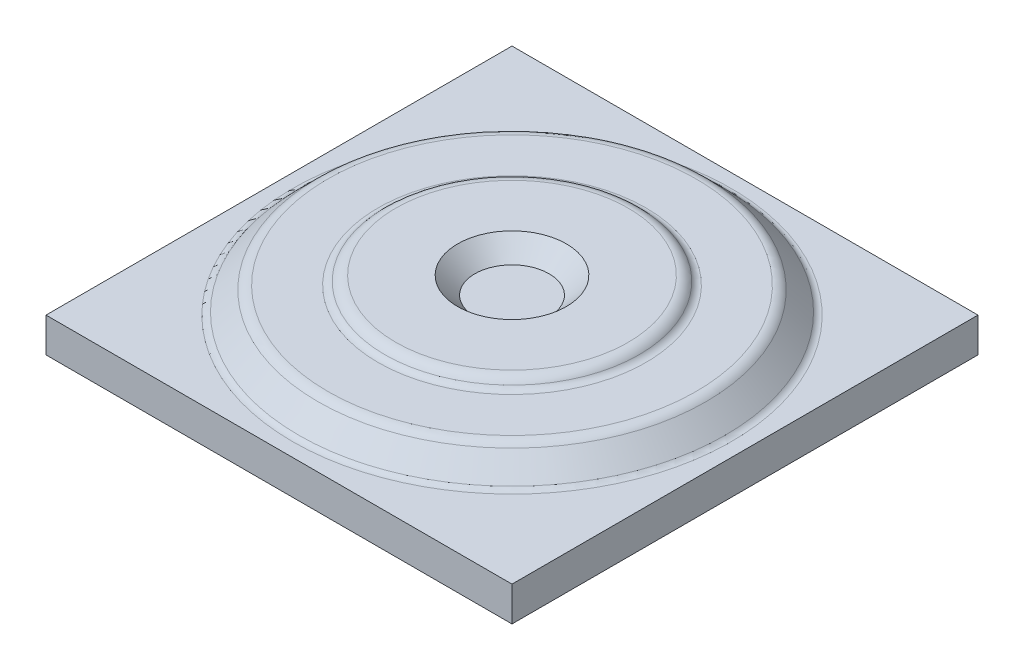
from build123d import *

# Parameters (mm, degrees)
SKETCH_1_W      = 270
SKETCH_1_H      = 270
EXTRUDE_1_DEPTH = 20
FILLET_1_R      = 5
FILLET_2_R      = 8


with BuildPart() as part:
    # 草图1 → 凸台-拉伸1 (new body)
    with BuildSketch(Plane(origin=(0, 0, 0), x_dir=(1, 0, 0), z_dir=(0, 1, 0))):
        Rectangle(SKETCH_1_W, SKETCH_1_H)
    extrude(amount=EXTRUDE_1_DEPTH)

    # 草图2 → 旋转1 (revolve)
    with BuildSketch(Plane.XY):
        Polygon((0, 20), (125, 20), (110, 35), (75, 35), (71.498962309, 40), (31.498962309, 40), (21.498962309, 30), (0, 30), align=None)
    revolve(axis=Axis((0, 0, 0), (0, 1, 0)))

    # 圆角1
    fillet_1_edges = [part.edges().sort_by_distance(p)[0] for p in [
        (-125, 20, 0),
        (-75, 35, 0),
    ]]
    fillet(fillet_1_edges, radius=FILLET_1_R)

    # 圆角2
    fillet_2_edges = [part.edges().sort_by_distance(p)[0] for p in [
        (-71.498962309, 40, 0),
        (-110, 35, 0),
    ]]
    fillet(fillet_2_edges, radius=FILLET_2_R)


solid = part.part
